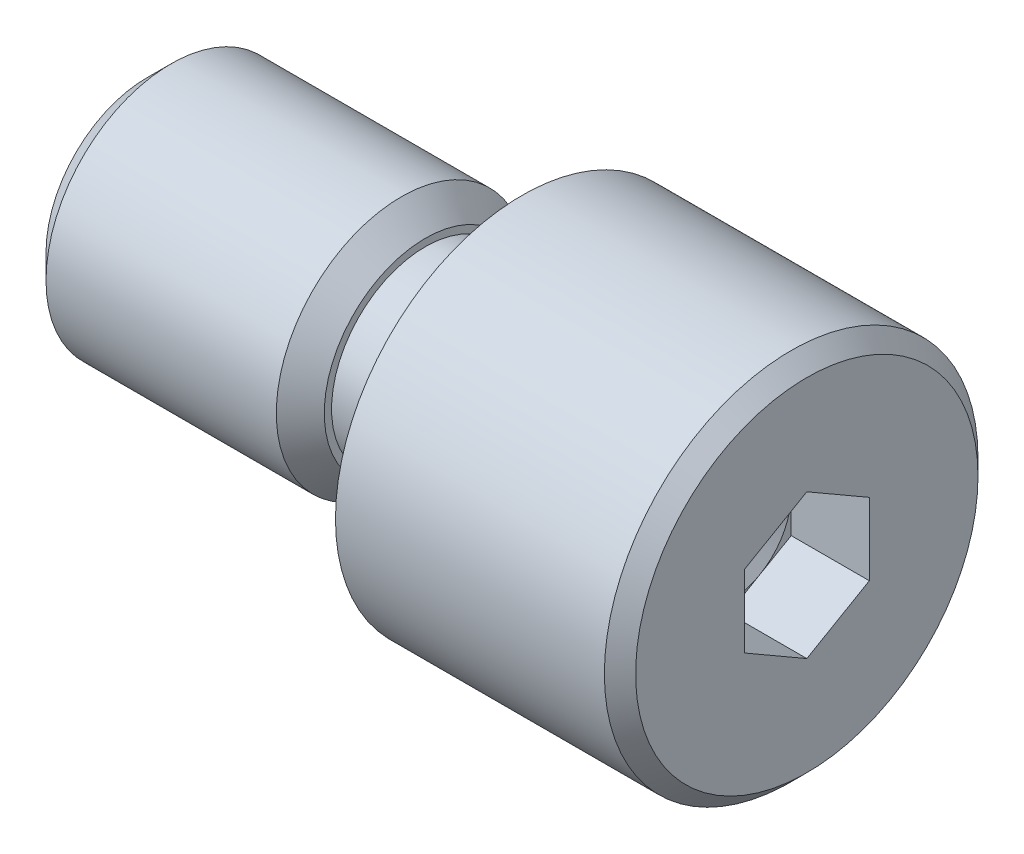
from build123d import *

# Parameters (mm, degrees)
CUT_EXTRUDE1_DEPTH = 2.5
CHAMFER1_SIZE      = 0.767
CHAMFER2_SIZE      = 0.5
FILLET1_R          = 0.2


with BuildPart() as part:
    # Sketch1 → Revolve1 (revolve)
    with BuildSketch(Plane.XY):
        Polygon((0, 4), (0, 0), (21.1, 0), (21.1, 5.975), (12, 5.975), (12, 3), (8.9, 3), (8.9, 4), align=None)
    revolve(axis=Axis((0, 0, 0), (1, 0, 0)))

    # Sketch2 → Cut-Extrude1 (cut)
    with BuildSketch(Plane(origin=(21.1, 0, 0), x_dir=(0, 0, -1), z_dir=(1, 0, 0))):
        Polygon((0, -2.309401077), (2, -1.154700538), (2, 1.154700538), (0, 2.309401077), (-2, 1.154700538), (-2, -1.154700538), align=None)
    extrude(amount=-CUT_EXTRUDE1_DEPTH, mode=Mode.SUBTRACT)

    # Sketch3 → Cut-Revolve1 (revolve, cut)
    with BuildSketch(Plane(origin=(0, 0, 0), x_dir=(-1, 0, 0), z_dir=(0, 0, -1))):
        Polygon((-18.6, 2), (-18.6, 0), (-17.445299462, 0), align=None)
    revolve(axis=Axis((18.600025, 0, 0), (-1, 0, 0)), mode=Mode.SUBTRACT)

    # Chamfer1
    chamfer1_edges = [part.edges().sort_by_distance(p)[0] for p in [
        (0, -4, 0),
        (8.9, -4, 0),
    ]]
    chamfer(chamfer1_edges, length=CHAMFER1_SIZE)

    # Chamfer2
    chamfer2_edges = [part.edges().sort_by_distance(p)[0] for p in [
        (21.1, -5.975, 0),
    ]]
    chamfer(chamfer2_edges, length=CHAMFER2_SIZE)

    # Fillet1
    fillet1_edges = [part.edges().sort_by_distance(p)[0] for p in [
        (12, -3, 0),
    ]]
    fillet(fillet1_edges, radius=FILLET1_R)


solid = part.part
